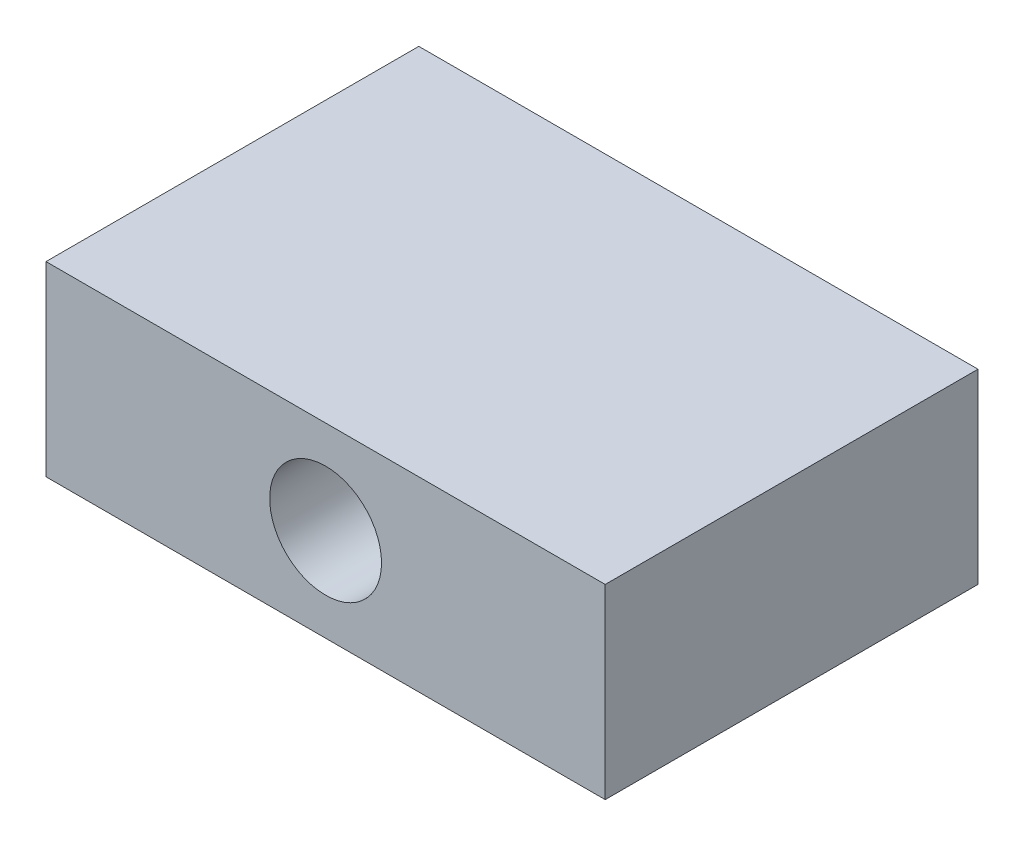
from build123d import *

# Parameters (mm, degrees)
SKIZZE1_W               = 20
SKIZZE1_H               = 10
LINEAR_AUSTRAGEN1_DEPTH = 30
SKIZZE2_R               = 3
LINEAR_AUSTRAGEN2_DEPTH = 21


with BuildPart() as part:
    # Skizze1 → Linear austragen1 (new body)
    with BuildSketch(Plane(origin=(0, 0, 0), x_dir=(0, 0, -1), z_dir=(1, 0, 0))):
        with Locations((10, 5)):
            Rectangle(SKIZZE1_W, SKIZZE1_H)
    extrude(amount=LINEAR_AUSTRAGEN1_DEPTH)

    # Skizze2 → Linear austragen2 (cut, through all)
    with BuildSketch(Plane.XY):
        with Locations((15, 5)):
            Circle(SKIZZE2_R)
    extrude(amount=-LINEAR_AUSTRAGEN2_DEPTH, mode=Mode.SUBTRACT)


solid = part.part
